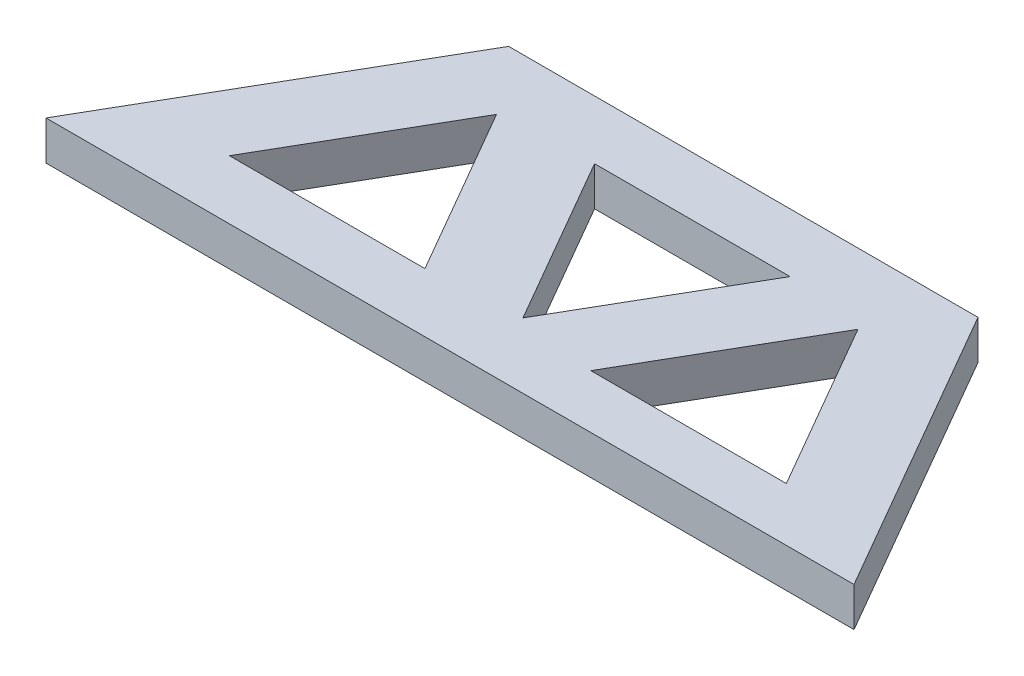
from build123d import *

# Parameters (mm, degrees)
BOSS_EXTRUDE1_DEPTH = 10


with BuildPart() as part:
    # Sketch1 → Boss-Extrude1 (new body)
    with BuildSketch(Plane(origin=(0, 0, 0), x_dir=(1, 0, 0), z_dir=(0, 1, 0))):
        Polygon((43.301270189, 75), (0, 0), (206.602540378, 0), (163.301270189, 75), align=None)
        Polygon((80.254006688, 60), (130.254006688, 60), (105.254006688, 16.698729811), align=None, mode=Mode.SUBTRACT)
        Polygon((125.601586083, 13.695227923), (150.601586083, 56.996498112), (175.601586083, 13.695227923), align=None, mode=Mode.SUBTRACT)
        Polygon((31.804368121, 15.086781489), (56.804368121, 58.388051678), (81.804368121, 15.086781489), align=None, mode=Mode.SUBTRACT)
    extrude(amount=BOSS_EXTRUDE1_DEPTH)


solid = part.part
